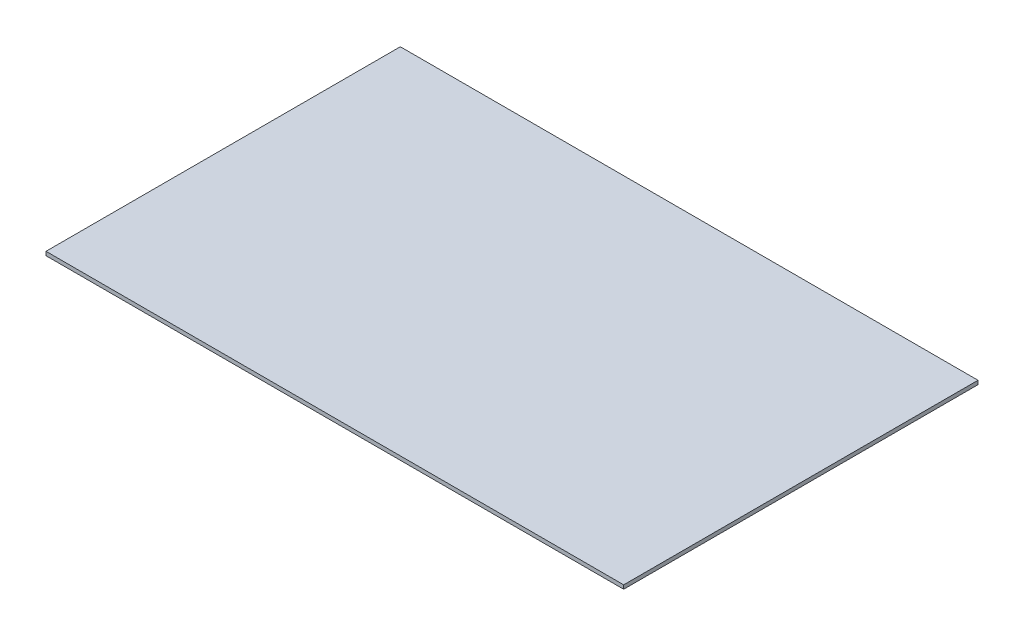
from build123d import *

# Parameters (mm, degrees)
SKETCH1_W           = 750
SKETCH1_H           = 460
BOSS_EXTRUDE1_DEPTH = 5


with BuildPart() as part:
    # Sketch1 → Boss-Extrude1 (new body)
    with BuildSketch(Plane(origin=(0, 0, 0), x_dir=(1, 0, 0), z_dir=(0, 1, 0))):
        with Locations((-375, 230)):
            Rectangle(SKETCH1_W, SKETCH1_H)
    extrude(amount=BOSS_EXTRUDE1_DEPTH)


solid = part.part
